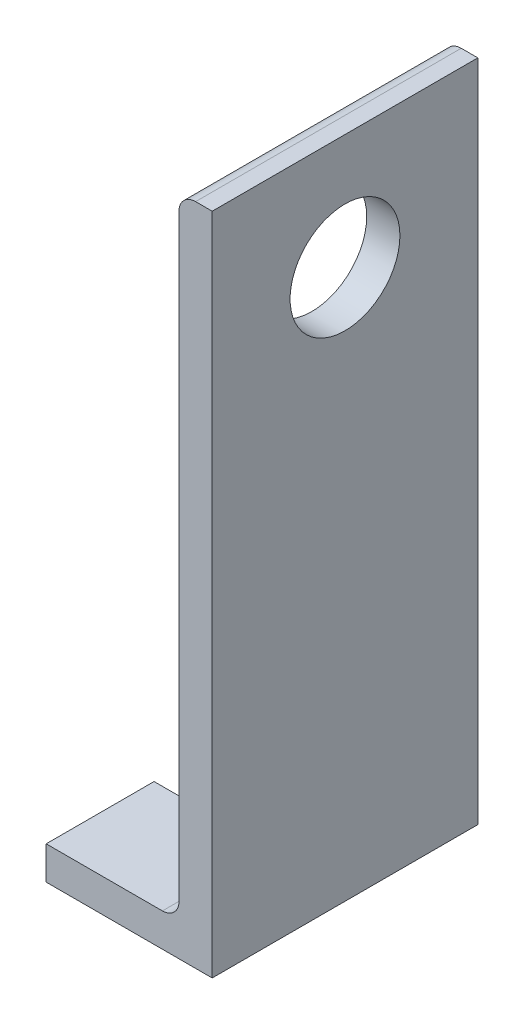
from build123d import *

# Parameters (mm, degrees)
BOSS_EXTRUDE1_DEPTH = 25.4
SKETCH3_R           = 4.765
CUT_EXTRUDE1_DEPTH  = 128
SKETCH5_R           = 10.5
CUT_EXTRUDE2_DEPTH  = 10
SKETCH6_W           = 11.049
SKETCH6_H           = 9.53
CUT_EXTRUDE3_DEPTH  = 10


with BuildPart() as part:
    # Sketch2 → Boss-Extrude1 (new body, symmetric)
    with BuildSketch(Plane.XY):
        with BuildLine():
            Line((-15.875, 0), (15.875, 0))
            Line((15.875, 0), (15.875, 127))
            Line((15.875, 127), (12.7, 127))
            ThreePointArc((12.7, 127), (10.45493597, 126.07006403), (9.525, 123.825))
            Line((9.525, 123.825), (9.525, 9.525))
            ThreePointArc((9.525, 9.525), (8.59506403, 7.27993597), (6.35, 6.35))
            Line((6.35, 6.35), (-12.7, 6.35))
            Line((-12.7, 6.35), (-15.875, 6.35))
            Line((-15.875, 6.35), (-15.875, 3.175))
            Line((-15.875, 3.175), (-15.875, 0))
        make_face()
    extrude(amount=BOSS_EXTRUDE1_DEPTH, both=True)

    # Sketch3 → Cut-Extrude1 (cut, through all)
    with BuildSketch(Plane.XZ):
        with Locations((-4.826, 0)):
            Circle(SKETCH3_R)
    extrude(amount=-CUT_EXTRUDE1_DEPTH, mode=Mode.SUBTRACT)

    # Sketch5 → Cut-Extrude2 (cut)
    with BuildSketch(Plane(origin=(15.875, 0, 0), x_dir=(0, 0, -1), z_dir=(1, 0, 0))):
        with Locations((0, 105)):
            Circle(SKETCH5_R)
    extrude(amount=-CUT_EXTRUDE2_DEPTH, mode=Mode.SUBTRACT)

    # Sketch6 → Cut-Extrude3 (cut)
    with BuildSketch(Plane.XZ):
        with Locations((-10.3505, 0)):
            Rectangle(SKETCH6_W, SKETCH6_H)
    extrude(amount=-CUT_EXTRUDE3_DEPTH, mode=Mode.SUBTRACT)


solid = part.part
